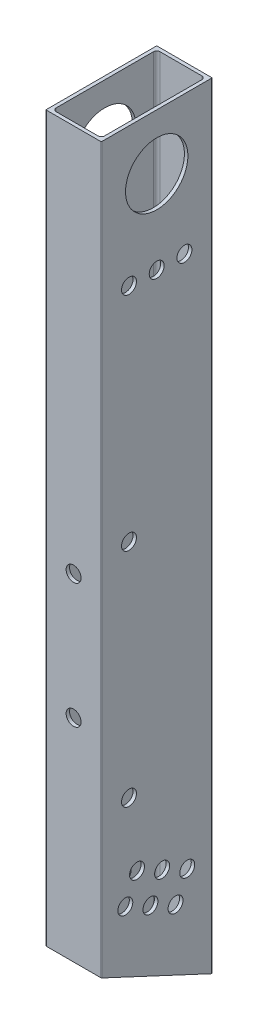
from build123d import *

# Parameters (mm, degrees)
BOSS_EXTRUDE1_DEPTH = 355.6
SKETCH2_R           = 3.429
SKETCH2_R_2         = 14.2875
CUT_EXTRUDE1_DEPTH  = 358.409680899
SKETCH3_R           = 3.429
CUT_EXTRUDE2_DEPTH  = 357.732126392


with BuildPart() as part:
    # Sketch1 → Boss-Extrude1 (new body)
    with BuildSketch(Plane(origin=(0, 0, 0), x_dir=(1, 0, 0), z_dir=(0, 1, 0))):
        with BuildLine():
            Line((-12.446, -25.4), (12.446, -25.4))
            ThreePointArc((12.446, -25.4), (12.625605122, -25.325605122), (12.7, -25.146))
            Line((12.7, -25.146), (12.7, 25.146))
            ThreePointArc((12.7, 25.146), (12.625605122, 25.325605122), (12.446, 25.4))
            Line((12.446, 25.4), (-12.446, 25.4))
            ThreePointArc((-12.446, 25.4), (-12.625605122, 25.325605122), (-12.7, 25.146))
            Line((-12.7, 25.146), (-12.7, -25.146))
            ThreePointArc((-12.7, -25.146), (-12.625605122, -25.325605122), (-12.446, -25.4))
        make_face()
        with BuildLine():
            Line((-9.5885, 23.8125), (9.5885, 23.8125))
            ThreePointArc((9.5885, 23.8125), (10.666130735, 23.366130735), (11.1125, 22.2885))
            Line((11.1125, 22.2885), (11.1125, -22.2885))
            ThreePointArc((11.1125, -22.2885), (10.666130735, -23.366130735), (9.5885, -23.8125))
            Line((9.5885, -23.8125), (-9.5885, -23.8125))
            ThreePointArc((-9.5885, -23.8125), (-10.666130735, -23.366130735), (-11.1125, -22.2885))
            Line((-11.1125, -22.2885), (-11.1125, 22.2885))
            ThreePointArc((-11.1125, 22.2885), (-10.666130735, 23.366130735), (-9.5885, 23.8125))
        make_face(mode=Mode.SUBTRACT)
    extrude(amount=BOSS_EXTRUDE1_DEPTH)

    # Sketch2 → Cut-Extrude1 (cut, through all)
    with BuildSketch(Plane.ZY.offset(12.7)):
        with Locations((-8.632581672, 35.844574716)):
            Circle(SKETCH2_R)
        with Locations((0, 330.2)):
            Circle(SKETCH2_R_2)
        with Locations((0, 292.1)):
            Circle(SKETCH2_R)
        with Locations((12.7, 292.1)):
            Circle(SKETCH2_R)
        with Locations((-12.7, 292.1)):
            Circle(SKETCH2_R)
        with Locations((2.877527224, 41.21182664)):
            Circle(SKETCH2_R)
        with Locations((14.387636119, 46.579078564)):
            Circle(SKETCH2_R)
        with Locations((-2.4897247, 52.721935535)):
            Circle(SKETCH2_R)
        with Locations((9.020384195, 58.089187459)):
            Circle(SKETCH2_R)
        with Locations((-13.999833596, 47.354683611)):
            Circle(SKETCH2_R)
        with Locations((12.7, 190.5)):
            Circle(SKETCH2_R)
        with Locations((12.7, 88.9)):
            Circle(SKETCH2_R)
        Polygon((-25.4, 0), (25.4, 23.688429034), (25.4, 0), align=None)
    extrude(amount=-CUT_EXTRUDE1_DEPTH, mode=Mode.SUBTRACT)

    # Sketch3 → Cut-Extrude2 (cut, through all)
    with BuildSketch(Plane.XY):
        with Locations((0, 177.8)):
            Circle(SKETCH3_R)
        with Locations((0, 120.65)):
            Circle(SKETCH3_R)
    extrude(amount=CUT_EXTRUDE2_DEPTH, mode=Mode.SUBTRACT)


solid = part.part
